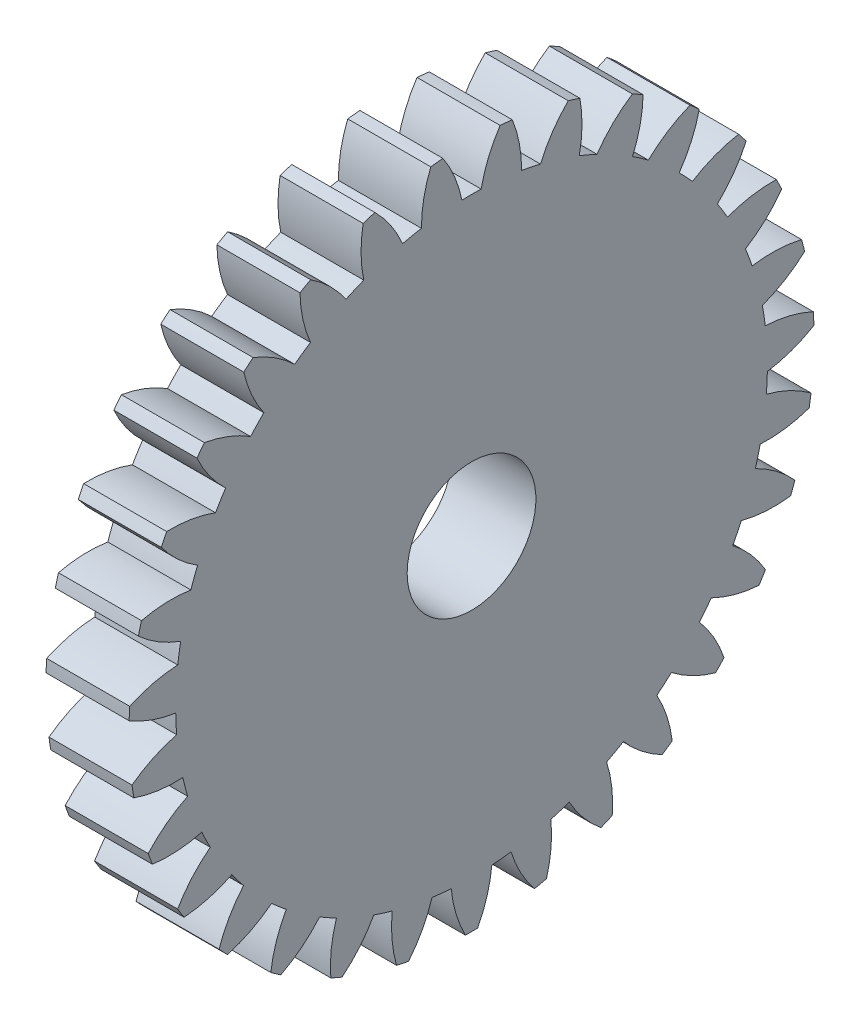
from build123d import *

# Parameters (mm, degrees)
BASPROSKE_W     = 4
BASPROSKE_H     = 16.5
TOOTHCUT_DEPTH  = 24.674881204
TEETHCUTS_COUNT = 31
TEETHCUTS_ANGLE = 348.387096774
BORSKE_R        = 3.1
BORE_DEPTH      = 50.0000508


with BuildPart() as part:
    # BasProSke → Base-Revolve (revolve)
    with BuildSketch(Plane(origin=(0, 0, 0), x_dir=(1, 0, 0), z_dir=(0, 1, 0)), mode=Mode.PRIVATE) as base_revolve_sk:
        with Locations((2, 8.25)):
            Rectangle(BASPROSKE_W, BASPROSKE_H)
    revolve(base_revolve_sk.sketch.rotate(Axis((-10, 0, 0), (1, 0, 0)), 180), axis=Axis((-10, 0, 0), (1, 0, 0)))

    # TooCutSke → ToothCut (cut, through all)
    with BuildSketch(Plane(origin=(0, 0, 0), x_dir=(0, 0, -1), z_dir=(1, 0, 0))):
        with BuildLine():
            ThreePointArc((0.464153838, 14.241438207), (0, 14.249), (-0.464153838, 14.241438207))
            ThreePointArc((-0.464153838, 14.241438207), (-0.818831014, 15.399587018), (-1.391915479, 16.466675938))
            ThreePointArc((-1.391915479, 16.466675938), (0, 16.5254), (1.391915479, 16.466675938))
            ThreePointArc((1.391915479, 16.466675938), (0.818831014, 15.399587018), (0.464153838, 14.241438207))
        make_face()
    toothcut = extrude(amount=TOOTHCUT_DEPTH, mode=Mode.SUBTRACT)

    # TeethCuts: ToothCut ×31 about axis
    teethcuts_axis = Axis((-10, 0, 0), (1, 0, 0))
    for i in range(1, TEETHCUTS_COUNT):
        add(toothcut.rotate(teethcuts_axis, i * TEETHCUTS_ANGLE / (TEETHCUTS_COUNT - 1)), mode=Mode.SUBTRACT)

    # BorSke → Bore (cut, symmetric)
    with BuildSketch(Plane(origin=(0, 0, 0), x_dir=(0, 0, -1), z_dir=(1, 0, 0))):
        with Locations(Location((0, 0, 0), (0, 0, 180))):
            Circle(BORSKE_R)
    extrude(amount=BORE_DEPTH, both=True, mode=Mode.SUBTRACT)


solid = part.part
